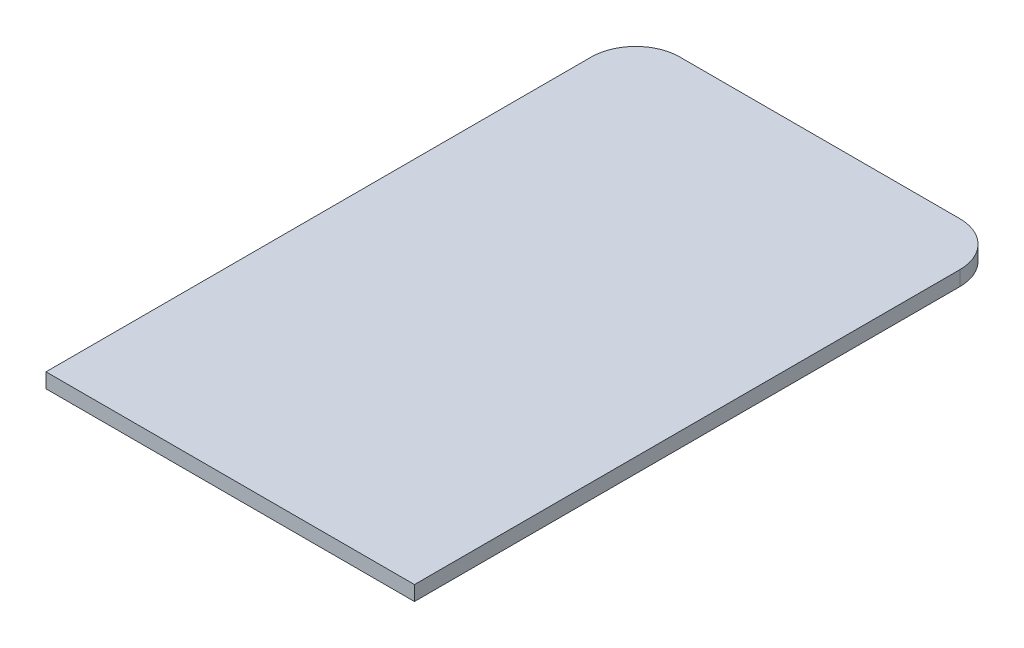
from build123d import *

# Parameters (mm, degrees)
BOSS_EXTRUDE1_DEPTH = 0.1


with BuildPart() as part:
    # Sketch1 → Boss-Extrude1 (new body)
    with BuildSketch(Plane(origin=(0, 0, 0), x_dir=(1, 0, 0), z_dir=(0, 1, 0))):
        with BuildLine():
            Line((0, 0), (1.25, 0))
            Line((1.25, 0), (1.25, 3.7))
            ThreePointArc((1.25, 3.7), (1.162132034, 3.912132034), (0.95, 4))
            Line((0.95, 4), (-0.95, 4))
            ThreePointArc((-0.95, 4), (-1.162132034, 3.912132034), (-1.25, 3.7))
            Line((-1.25, 3.7), (-1.25, 0))
            Line((-1.25, 0), (0, 0))
        make_face()
    extrude(amount=BOSS_EXTRUDE1_DEPTH)


solid = part.part
